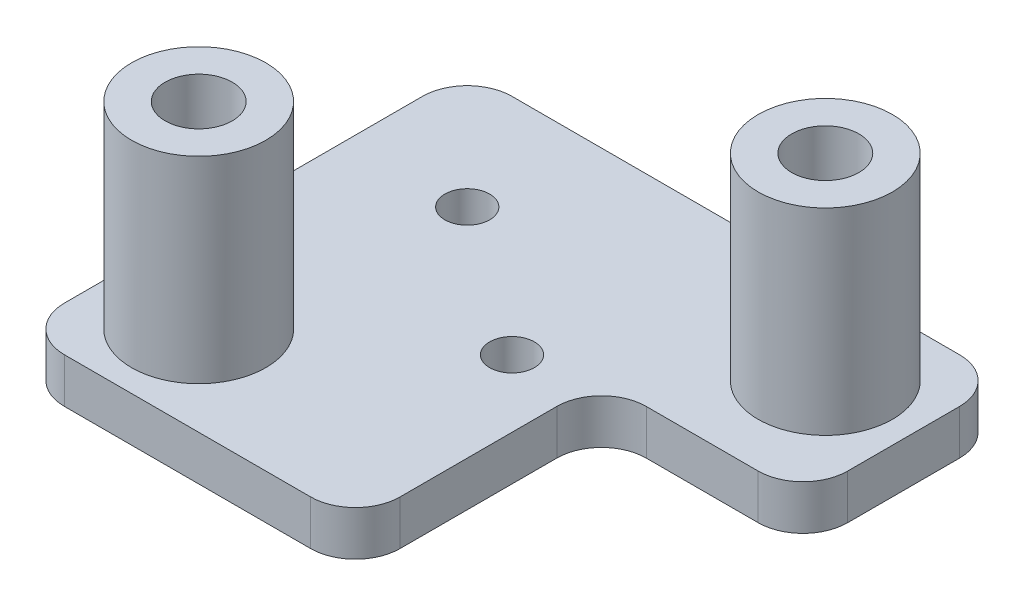
from build123d import *

# Parameters (mm, degrees)
CROQUIS1_R                = 1.5
SALIENTE_EXTRUIR1_DEPTH   = 1
CROQUIS2_R                = 1.5
SALIENTE_EXTRUIR2_DEPTH   = 4.4
SALIENTE_EXTRUIR2_2_DEPTH = 4.4
CROQUIS3_R                = 0.75
CORTAR_EXTRUIR1_DEPTH     = 8
REDONDEO1_R               = 1
CROQUIS4_R                = 1.5
CROQUIS4_R_2              = 0.75
SALIENTE_EXTRUIR3_DEPTH   = 1
CROQUIS5_R                = 0.5
CORTAR_EXTRUIR2_DEPTH     = 1


with BuildPart() as part:
    # Croquis1 → Saliente-Extruir1 (new body)
    with BuildSketch(Plane(origin=(0, 0, 0), x_dir=(1, 0, 0), z_dir=(0, 1, 0))):
        Polygon((-6, 5), (6, 5), (6, 0.5), (1.5, 0.5), (1.5, -5), (-6, -5), align=None)
        with Locations((4, 3)):
            Circle(CROQUIS1_R, mode=Mode.SUBTRACT)
        with Locations((-4, -3)):
            Circle(CROQUIS1_R, mode=Mode.SUBTRACT)
    extrude(amount=SALIENTE_EXTRUIR1_DEPTH)

    # Redondeo1
    redondeo1_edges = [part.edges().sort_by_distance(p)[0] for p in [
        (-6, 0.5, -5),
        (6, 0.5, -5),
        (6, 0.5, -0.5),
        (1.5, 0.5, -0.5),
        (1.5, 0.5, 5),
        (-6, 0.5, 5),
    ]]
    fillet(redondeo1_edges, radius=REDONDEO1_R)

    # Croquis5 → Cortar-Extruir2 (cut)
    with BuildSketch(Plane(origin=(0, 1, 0), x_dir=(1, 0, 0), z_dir=(0, 1, 0))):
        with Locations((-3.36, 2.36)):
            Circle(CROQUIS5_R)
        Circle(CROQUIS5_R)
    extrude(amount=-CORTAR_EXTRUIR2_DEPTH, mode=Mode.SUBTRACT)


with BuildPart() as body_2:
    # Croquis2 → Saliente-Extruir2 (new body)
    with BuildSketch(Plane(origin=(0, 1, 0), x_dir=(1, 0, 0), z_dir=(0, 1, 0))):
        with Locations((4, 3)):
            Circle(CROQUIS2_R)
    extrude(amount=SALIENTE_EXTRUIR2_DEPTH)


with BuildPart() as body_3:
    # Croquis2 → Saliente-Extruir2 2 (new body)
    with BuildSketch(Plane(origin=(0, 1, 0), x_dir=(1, 0, 0), z_dir=(0, 1, 0))):
        with Locations((-4, -3)):
            Circle(CROQUIS2_R)
    extrude(amount=SALIENTE_EXTRUIR2_2_DEPTH)


with BuildPart() as cortar_extruir1_tool:
    # Croquis3 → Cortar-Extruir1 (new body)
    with BuildSketch(Plane(origin=(0, 5.4, 0), x_dir=(1, 0, 0), z_dir=(0, 1, 0))):
        with Locations((4, 3)):
            Circle(CROQUIS3_R)
        with Locations((-4, -3)):
            Circle(CROQUIS3_R)
    extrude(amount=-CORTAR_EXTRUIR1_DEPTH)


with BuildPart() as body_2_1:
    add(body_2.part)

    # Cortar-Extruir1: cut by cortar_extruir1_tool
    add(cortar_extruir1_tool.part, mode=Mode.SUBTRACT)


with BuildPart() as body_3_1:
    add(body_3.part)

    # Cortar-Extruir1: cut by cortar_extruir1_tool
    add(cortar_extruir1_tool.part, mode=Mode.SUBTRACT)


    add(body_2_1.part)  # Saliente-Extruir3 merges body 2
    # Croquis4 → Saliente-Extruir3 (add)
    with BuildSketch(Plane.XZ.offset(-1)):
        with Locations((4, -3)):
            Circle(CROQUIS4_R)
        with Locations((4, -3)):
            Circle(CROQUIS4_R_2, mode=Mode.SUBTRACT)
        with Locations((-4, 3)):
            Circle(CROQUIS4_R)
        with Locations((-4, 3)):
            Circle(CROQUIS4_R_2, mode=Mode.SUBTRACT)
    extrude(amount=SALIENTE_EXTRUIR3_DEPTH)


solid = Compound([part.part, body_3_1.part])
